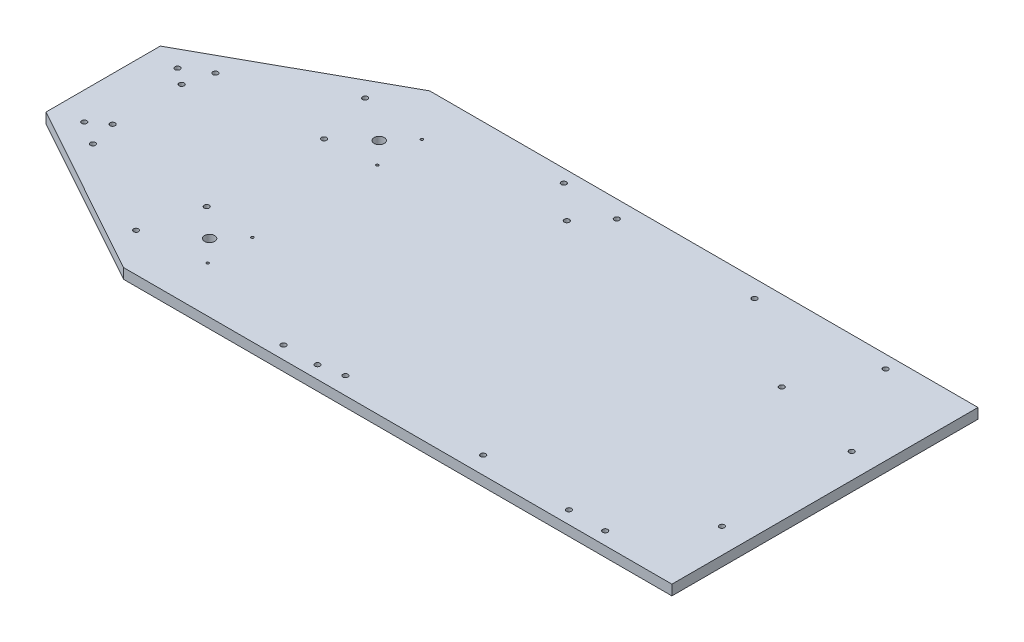
from build123d import *

# Parameters (mm, degrees)
BOSS_EXTRUDE1_DEPTH = 6.35
SKETCH4_R           = 1.5875
SKETCH4_R_2         = 0.79502
SKETCH4_R_3         = 3.175
CUT_EXTRUDE1_DEPTH  = 7.35


with BuildPart() as part:
    # Sketch2 → Boss-Extrude1 (new body)
    with BuildSketch(Plane(origin=(0, 0, 0), x_dir=(1, 0, 0), z_dir=(0, 1, 0))):
        Polygon((-264.543396226, 98.724528302), (-264.543396226, 27.604528302), (-156.593396226, -32.085471698), (184.719103774, -32.085471698), (184.719103774, 158.414528302), (-156.593396226, 158.414528302), align=None)
    extrude(amount=BOSS_EXTRUDE1_DEPTH)

    # Sketch4 → Cut-Extrude1 (cut, through all)
    with BuildSketch(Plane(origin=(0, 6.35, 0), x_dir=(1, 0, 0), z_dir=(0, 1, 0))):
        with Locations((135.189103774, 150.413528302)):
            Circle(SKETCH4_R)
        with Locations((169.098103774, 14.650528302)):
            Circle(SKETCH4_R)
        with Locations((169.098103774, 95.422528302)):
            Circle(SKETCH4_R)
        with Locations((112.583103774, 108.376528302)):
            Circle(SKETCH4_R)
        with Locations((56.449103774, 147.619528302)):
            Circle(SKETCH4_R)
        with Locations((-29.275896226, 147.619528302)):
            Circle(SKETCH4_R)
        with Locations((-65.064496226, 150.413528302)):
            Circle(SKETCH4_R)
        with Locations((-43.880896226, 131.109528302)):
            Circle(SKETCH4_R)
        with Locations((-132.780896226, 129.839528302)):
            Circle(SKETCH4_R_2)
        with Locations((-132.780896226, 102.058278302)):
            Circle(SKETCH4_R_2)
        with Locations((-145.501812631, 115.948903302)):
            Circle(SKETCH4_R_3)
        with Locations((-237.238396226, 84.754528302)):
            Circle(SKETCH4_R)
        with Locations((-237.238396226, 41.759679404)):
            Circle(SKETCH4_R)
        with Locations((-163.578396226, 26.652028302)):
            Circle(SKETCH4_R)
        with Locations((-163.578396226, 99.677028302)):
            Circle(SKETCH4_R)
        with Locations((-247.271396226, 34.139679404)):
            Circle(SKETCH4_R)
        with Locations((-247.271396226, 92.1893772)):
            Circle(SKETCH4_R)
        with Locations((-232.793396226, 25.064528302)):
            Circle(SKETCH4_R)
        with Locations((-172.777199478, -8.120898136)):
            Circle(SKETCH4_R)
        with Locations((-172.777199478, 134.449954739)):
            Circle(SKETCH4_R)
        with Locations((-232.793396226, 101.264528302)):
            Circle(SKETCH4_R)
        with Locations((-132.780896226, -3.510471698)):
            Circle(SKETCH4_R_2)
        with Locations((-132.780896226, 24.270778302)):
            Circle(SKETCH4_R_2)
        with Locations((-145.501812631, 10.380153302)):
            Circle(SKETCH4_R_3)
        with Locations((-43.880896226, -24.084471698)):
            Circle(SKETCH4_R)
        with Locations((-29.275896226, -21.290471698)):
            Circle(SKETCH4_R)
        with Locations((56.449103774, -21.290471698)):
            Circle(SKETCH4_R)
        with Locations((135.189103774, -24.084471698)):
            Circle(SKETCH4_R)
        with Locations((112.583103774, -24.084471698)):
            Circle(SKETCH4_R)
        with Locations((-65.064496226, -24.084471698)):
            Circle(SKETCH4_R)
    extrude(amount=-CUT_EXTRUDE1_DEPTH, mode=Mode.SUBTRACT)


solid = part.part
